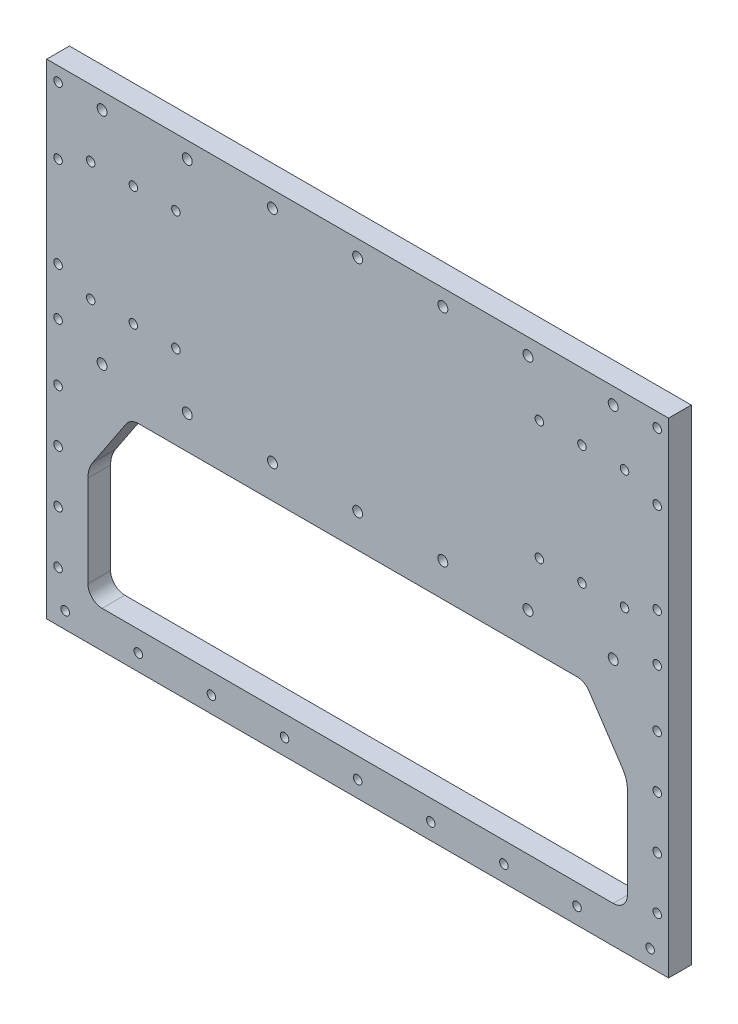
from build123d import *
from build123d.topology import SkipClean

# Parameters (mm, degrees)
ESQUISSE1_R        = 3
ESQUISSE1_R_2      = 3.5
BOSS_EXTRU_1_DEPTH = 8
CHANFREIN1_SIZE    = 4


with BuildPart() as part:
    # Esquisse1 → Boss.-Extru.1 (new body, symmetric)
    with BuildSketch(Plane.XY):
        with BuildLine():
            Line((0, 9.5), (0, -2))
            ThreePointArc((0, -2), (3, -5), (0, -8))
            Line((0, -8), (0, -16.5))
            Line((0, -16.5), (219, -16.5))
            Line((219, -16.5), (219, 325))
            Line((219, 325), (0, 325))
            Line((0, 325), (0, 317))
            ThreePointArc((0, 317), (3.5, 313.5), (0, 310))
            Line((0, 310), (0, 162))
            ThreePointArc((0, 162), (3.5, 158.5), (0, 155))
            Line((0, 155), (0, 135))
            Line((0, 135), (154.64816242, 135))
            ThreePointArc((154.64816242, 135), (159.366741675, 133.816745988), (162.968665363, 130.547001962))
            Line((162.968665363, 130.547001962), (186.641005887, 95.03849117))
            ThreePointArc((186.641005887, 95.03849117), (189.14184053, 89.740170219), (190, 83.944487245))
            Line((190, 83.944487245), (190, 19.5))
            ThreePointArc((190, 19.5), (187.071067812, 12.428932188), (180, 9.5))
            Line((180, 9.5), (0, 9.5))
        make_face()
        with Locations((188, 278)):
            Circle(ESQUISSE1_R, mode=Mode.SUBTRACT)
        with Locations((158, 278)):
            Circle(ESQUISSE1_R, mode=Mode.SUBTRACT)
        with Locations((128, 278)):
            Circle(ESQUISSE1_R, mode=Mode.SUBTRACT)
        with Locations((51.5, -5)):
            Circle(ESQUISSE1_R, mode=Mode.SUBTRACT)
        with Locations((103, -5)):
            Circle(ESQUISSE1_R, mode=Mode.SUBTRACT)
        with Locations((154.5, -5)):
            Circle(ESQUISSE1_R, mode=Mode.SUBTRACT)
        with Locations((206, -5)):
            Circle(ESQUISSE1_R, mode=Mode.SUBTRACT)
        with Locations((128, 194)):
            Circle(ESQUISSE1_R, mode=Mode.SUBTRACT)
        with Locations((158, 194)):
            Circle(ESQUISSE1_R, mode=Mode.SUBTRACT)
        with Locations((188, 194)):
            Circle(ESQUISSE1_R, mode=Mode.SUBTRACT)
        with Locations((211, 268)):
            Circle(ESQUISSE1_R, mode=Mode.SUBTRACT)
        with Locations((211, 130)):
            Circle(ESQUISSE1_R, mode=Mode.SUBTRACT)
        with Locations((211, 93)):
            Circle(ESQUISSE1_R, mode=Mode.SUBTRACT)
        with Locations((211, 170.5)):
            Circle(ESQUISSE1_R, mode=Mode.SUBTRACT)
        with Locations((211, 315)):
            Circle(ESQUISSE1_R, mode=Mode.SUBTRACT)
        with Locations((211, 56)):
            Circle(ESQUISSE1_R, mode=Mode.SUBTRACT)
        with Locations((211, 19)):
            Circle(ESQUISSE1_R, mode=Mode.SUBTRACT)
        with Locations((211, 204)):
            Circle(ESQUISSE1_R, mode=Mode.SUBTRACT)
        with Locations((60, 158.5)):
            Circle(ESQUISSE1_R_2, mode=Mode.SUBTRACT)
        with Locations((120, 158.5)):
            Circle(ESQUISSE1_R_2, mode=Mode.SUBTRACT)
        with Locations((180, 158.5)):
            Circle(ESQUISSE1_R_2, mode=Mode.SUBTRACT)
        with Locations((180, 313.5)):
            Circle(ESQUISSE1_R_2, mode=Mode.SUBTRACT)
        with Locations((60, 313.5)):
            Circle(ESQUISSE1_R_2, mode=Mode.SUBTRACT)
        with Locations((120, 313.5)):
            Circle(ESQUISSE1_R_2, mode=Mode.SUBTRACT)
    boss_extru_1 = extrude(amount=BOSS_EXTRU_1_DEPTH, both=True)

    # Sym_trie1: Boss.-Extru.1 across plane
    with SkipClean():  # keep this step's faces unmerged: merging them makes the solid invalid here
        add(boss_extru_1.mirror(Plane(origin=(0, 0, 0), x_dir=(0, 0, 1), z_dir=(1, 0, 0))))

    # Chanfrein1
    chanfrein1_edges = [part.edges().sort_by_distance(p)[0] for p in [
        (-48.5, -5, -8),
        (-100, -5, -8),
        (-151.5, -5, -8),
        (-203, -5, -8),
        (3, -5, -8),
        (48.5, -5, -8),
        (100, -5, -8),
        (151.5, -5, -8),
        (203, -5, -8),
    ]]
    chamfer(chanfrein1_edges, length=CHANFREIN1_SIZE)


solid = part.part
